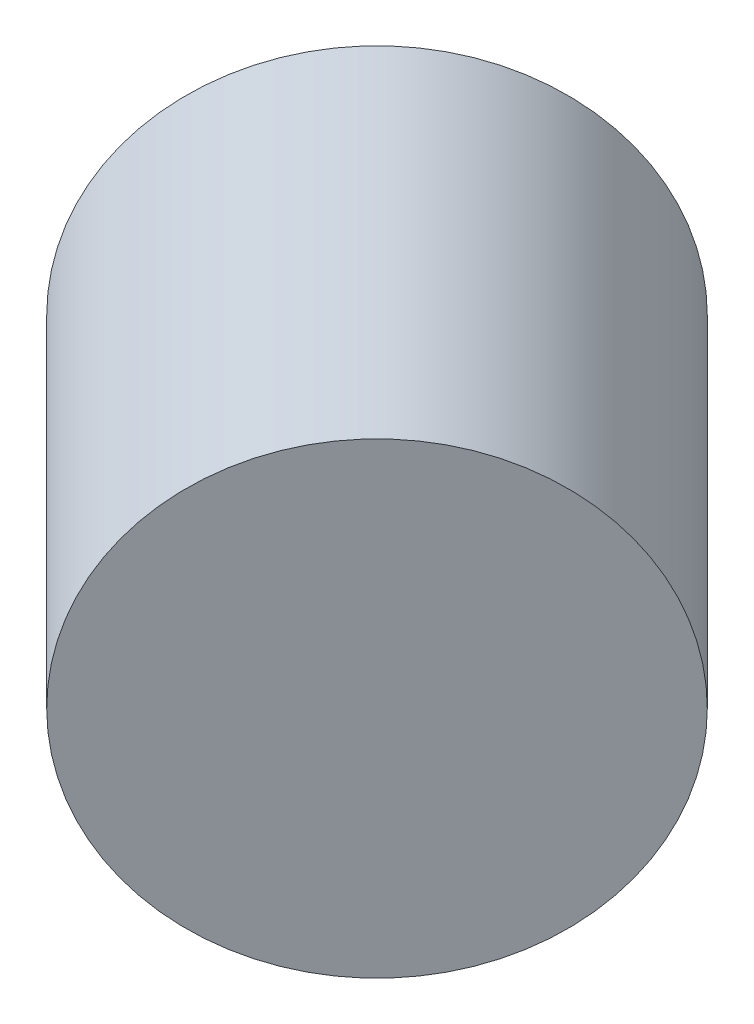
from build123d import *

# Parameters (mm, degrees)
SKETCH1_R           = 49
BOSS_EXTRUDE1_DEPTH = 101


with BuildPart() as part:
    # Sketch1 → Boss-Extrude1 (new body)
    with BuildSketch(Plane(origin=(-155.855354978, 0, -155.855354978), x_dir=(-0.707106781, 0, 0.707106781), z_dir=(-0.707106781, 0, -0.707106781))):
        with Locations((-558.507949545, -7.5)):
            Circle(SKETCH1_R)
    extrude(amount=-BOSS_EXTRUDE1_DEPTH)


solid = part.part
